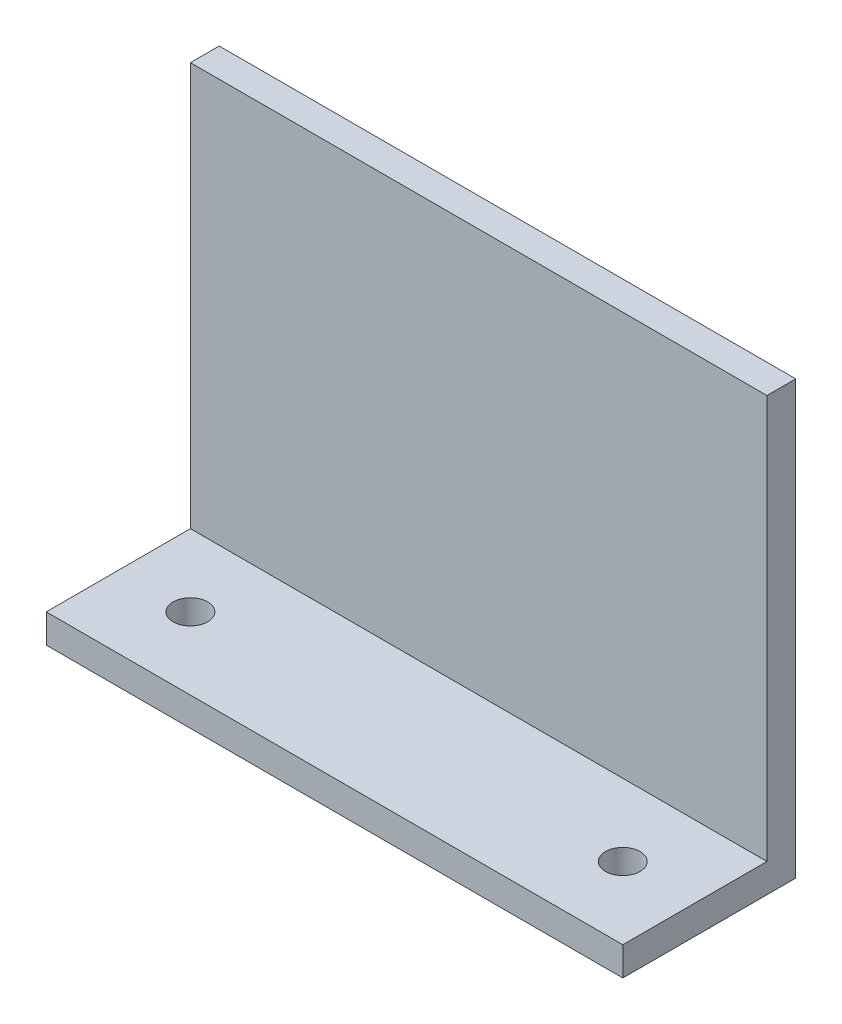
from build123d import *

# Parameters (mm, degrees)
SZKIC1_W                    = 200
SZKIC1_H                    = 150
DODANIE_WYCI_GNI_CIE1_DEPTH = 10
SZKIC2_W                    = 200
SZKIC2_H                    = 10
DODANIE_WYCI_GNI_CIE2_DEPTH = 50
OTW_R_POD_RUB_M101_D        = 12
SZYK_LINIOWY2_COUNT         = 2
SZYK_LINIOWY2_PITCH         = 150


with BuildPart() as part:
    # Szkic1 → Dodanie-wyciągnięcie1 (new body)
    with BuildSketch(Plane.XY):
        Rectangle(SZKIC1_W, SZKIC1_H)
    extrude(amount=DODANIE_WYCI_GNI_CIE1_DEPTH)

    # Szkic2 → Dodanie-wyciągnięcie2 (add)
    with BuildSketch(Plane.XY.offset(10)):
        with Locations((0, -70)):
            Rectangle(SZKIC2_W, SZKIC2_H)
    extrude(amount=DODANIE_WYCI_GNI_CIE2_DEPTH)

    # Otwór pod śrubę M101 (through all)
    with Locations(Plane(origin=(0, -65, 0), x_dir=(1, 0, 0), z_dir=(0, 1, 0))):
        with Locations((-75, -35)):
            otw_r_pod_rub_m101 = Hole(OTW_R_POD_RUB_M101_D / 2)

    # Szyk liniowy2: Otwór pod śrubę M101 ×2
    with Locations(*[(i * SZYK_LINIOWY2_PITCH, 0, 0) for i in range(1, SZYK_LINIOWY2_COUNT)]):
        add(otw_r_pod_rub_m101, mode=Mode.SUBTRACT)


solid = part.part
